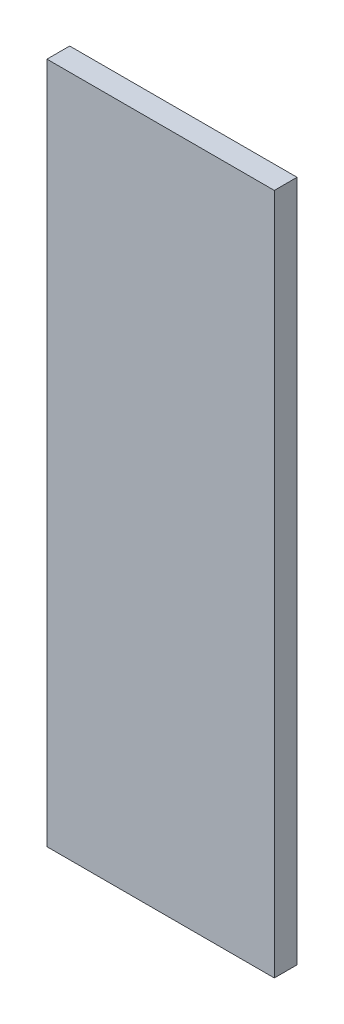
from build123d import *

# Parameters (mm, degrees)
SCHIZZO1_W                   = 10
SCHIZZO1_H                   = 30
ESTRUSIONE_ESTRUSIONE1_DEPTH = 1


with BuildPart() as part:
    # Schizzo1 → Estrusione-Estrusione1 (new body)
    with BuildSketch(Plane.XY):
        Rectangle(SCHIZZO1_W, SCHIZZO1_H)
    extrude(amount=ESTRUSIONE_ESTRUSIONE1_DEPTH)


solid = part.part
